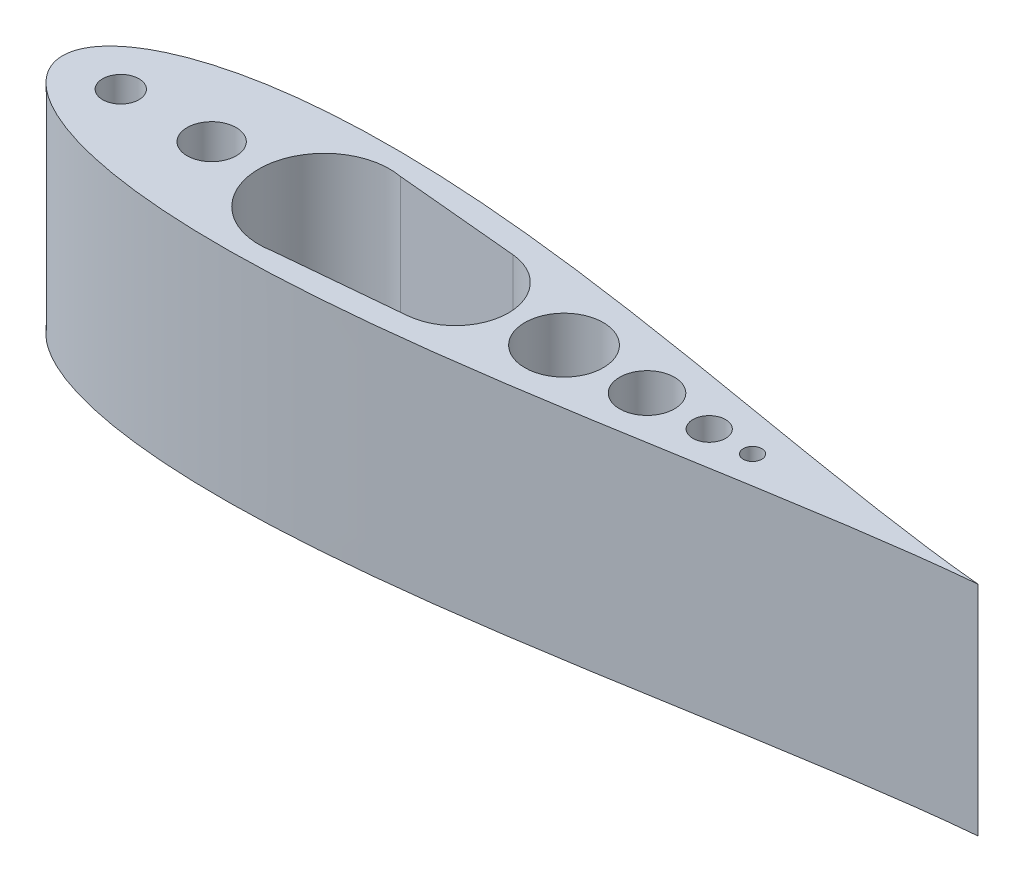
from build123d import *

# Parameters (mm, degrees)
SKETCH1_R           = 6.392333333
SKETCH1_R_2         = 3.81
SKETCH1_R_3         = 2.159
BOSS_EXTRUDE1_DEPTH = 50.8


with BuildPart() as part:
    # Sketch1 → Boss-Extrude1 (new body)
    with BuildSketch(Plane(origin=(0, 0, 0), x_dir=(1, 0, 0), z_dir=(0, 1, 0))):
        with BuildLine():
            add(Edge.make_bspline(
                [(-106.482983395, 7e-09), (-106.481988205, 0.336221447), (-106.427915569, 1.172470852), (-106.105951464, 2.643099269), (-105.314009735, 4.475217408), (-103.897531119, 6.504348419), (-101.808045378, 8.571651332), (-99.066717841, 10.567556704), (-95.719803188, 12.4267473), (-91.817332429, 14.111441711), (-87.406701835, 15.599318162), (-82.531907012, 16.877133323), (-77.234149654, 17.93743562), (-71.552607098, 18.776740572), (-65.525147606, 19.395460586), (-59.188591418, 19.79657403), (-52.57905308, 19.986276316), (-45.732001964, 19.972865837), (-38.682363694, 19.76732247), (-31.464522928, 19.382552478), (-24.112335149, 18.833317467), (-16.659115821, 18.136000968), (-9.137634043, 17.308302017), (-1.580112881, 16.368906014), (5.98177291, 15.337213534), (13.516891029, 14.232999407), (20.994645609, 13.076129848), (28.384968739, 11.886210001), (35.658323251, 10.682336314), (42.785702907, 9.482759124), (49.738647425, 8.304637787), (56.489265684, 7.163760718), (63.010281114, 6.074356699), (69.275076728, 5.048841412), (75.257781106, 4.097692071), (80.933343311, 3.229317249), (86.277669376, 2.449846213), (91.267618323, 1.763292049), (95.881607116, 1.17122476), (100.098099776, 0.673119164), (103.673185129, 0.290516392), (105.83614122, 0.081745654), (106.733370691, 7e-09)],
                knots=[0.5, 0.5, 0.5, 0.5, 0.502166769, 0.505390167, 0.509655974, 0.514947682, 0.521244711, 0.528520886, 0.536744945, 0.54588136, 0.555890751, 0.566730119, 0.57835299, 0.590709588, 0.603747039, 0.617409572, 0.631638768, 0.646373793, 0.661551658, 0.677107483, 0.692974771, 0.709085713, 0.725371443, 0.741762353, 0.758188398, 0.774579367, 0.790865214, 0.806976332, 0.822843867, 0.838400002, 0.853578262, 0.868313774, 0.882543568, 0.896206835, 0.909245173, 0.92160287, 0.933227116, 0.944068236, 0.954079898, 0.963219316, 0.971447445, 0.977251074, 0.977251074, 0.977251074, 0.977251074], degree=3))
            add(Edge.make_bspline(
                [(-106.482983395, -7e-09), (-106.481988205, -0.336221447), (-106.427915569, -1.172470852), (-106.105951463, -2.643099269), (-105.314009735, -4.475217408), (-103.897531118, -6.504348419), (-101.808045378, -8.571651332), (-99.06671784, -10.567556704), (-95.719803188, -12.4267473), (-91.817332429, -14.111441711), (-87.406701835, -15.599318162), (-82.531907011, -16.877133323), (-77.273170777, -17.929625865), (-73.632382766, -18.469484174), (-71.77044662, -18.70528518)],
                knots=[0.5, 0.5, 0.5, 0.5, 0.502166769, 0.505390167, 0.509655974, 0.514947682, 0.521244711, 0.528520886, 0.536744945, 0.54588136, 0.555890751, 0.566730119, 0.57835299, 0.590453127, 0.590453127, 0.590453127, 0.590453127], degree=3))
            add(Edge.make_bspline(
                [(-71.77044662, -18.70528518), (-71.730983039, -18.710282963), (-69.685237287, -18.968426485), (-65.525147605, -19.395460586), (-59.188591417, -19.79657403), (-52.57905308, -19.986276316), (-45.732001964, -19.972865837), (-38.682363694, -19.76732247), (-31.464522928, -19.382552478), (-24.112335148, -18.833317467), (-16.659115821, -18.136000968), (-9.137634043, -17.308302017), (-1.580112881, -16.368906014), (5.98177291, -15.337213534), (13.516891029, -14.232999407), (20.99464561, -13.076129848), (28.384968739, -11.886210001), (35.658323251, -10.682336314), (42.785702907, -9.482759124), (49.738647426, -8.304637787), (56.489265684, -7.163760718), (63.010281115, -6.074356699), (69.275076728, -5.048841412), (75.257781106, -4.097692071), (80.933343311, -3.229317249), (86.277669376, -2.449846213), (91.267618323, -1.763292049), (95.881607116, -1.17122476), (100.098099776, -0.673119164), (103.673185129, -0.290516392), (105.83614122, -0.081745654), (106.733370691, -7e-09)],
                knots=[0.590453127, 0.590453127, 0.590453127, 0.590453127, 0.590709588, 0.603747039, 0.617409572, 0.631638768, 0.646373793, 0.661551658, 0.677107483, 0.692974771, 0.709085713, 0.725371443, 0.741762353, 0.758188398, 0.774579367, 0.790865214, 0.806976332, 0.822843867, 0.838400002, 0.853578262, 0.868313774, 0.882543568, 0.896206835, 0.909245173, 0.92160287, 0.933227116, 0.944068236, 0.954079898, 0.963219316, 0.971447445, 0.977251074, 0.977251074, 0.977251074, 0.977251074], degree=3))
        make_face()
        with BuildLine():
            ThreePointArc((-88.703779951, 0), (-92.937113284, -4.233333333), (-97.170446617, 0))
            ThreePointArc((-97.170446617, 0), (-92.937113284, 4.233333333), (-88.703779951, 0))
        make_face(mode=Mode.SUBTRACT)
        with BuildLine():
            ThreePointArc((-66.05544662, 0), (-67.729331365, -4.041115254), (-71.77044662, -5.715))
            ThreePointArc((-71.77044662, -5.715), (-75.811561874, 4.041115254), (-66.05544662, 0))
        make_face(mode=Mode.SUBTRACT)
        with BuildLine():
            ThreePointArc((-45.540838593, -15.24), (-56.317145938, -10.776307345), (-60.780838593, 0))
            ThreePointArc((-60.780838593, 0), (-56.317145938, 10.776307345), (-45.540838593, 15.24))
            ThreePointArc((-45.540838593, 15.24), (-44.126098565, 15.174192257), (-42.723576496, 14.977337356))
            Line((-42.723576496, 14.977337356), (-13.847320134, 12.285108666))
            ThreePointArc((-13.847320134, 12.285108666), (-5.872176435, 8.309742362), (-2.65431439, 0))
            ThreePointArc((-2.65431439, 0), (-5.872176435, -8.309742362), (-13.847320134, -12.285108666))
            Line((-13.847320134, -12.285108666), (-42.723576496, -14.977337356))
            ThreePointArc((-42.723576496, -14.977337356), (-44.126098565, -15.174192257), (-45.540838593, -15.24))
        make_face(mode=Mode.SUBTRACT)
        with BuildLine():
            ThreePointArc((19.441184097, 0), (10.310172634, -9.131011462), (1.179161172, 0))
            ThreePointArc((1.179161172, 0), (10.310172634, 9.131011462), (19.441184097, 0))
        make_face(mode=Mode.SUBTRACT)
        with Locations((29.643517429, 0)):
            Circle(SKETCH1_R, mode=Mode.SUBTRACT)
        with Locations((44.126269567, 0)):
            Circle(SKETCH1_R_2, mode=Mode.SUBTRACT)
        with Locations((54.210398224, 0)):
            Circle(SKETCH1_R_3, mode=Mode.SUBTRACT)
    extrude(amount=BOSS_EXTRUDE1_DEPTH)


solid = part.part
